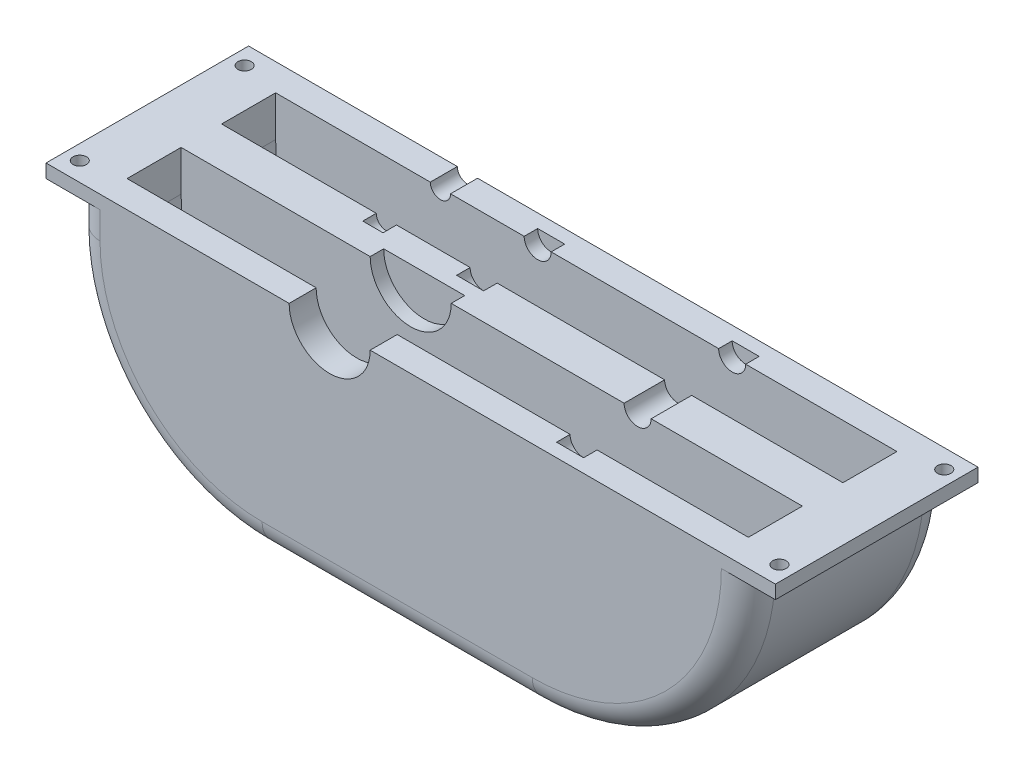
from build123d import *

# Parameters (mm, degrees)
BOSS_EXTRUDE1_DEPTH     = 37.5
SHELL1_T                = -10
SKETCH2_W               = 230
SKETCH2_H               = 15
BOSS_EXTRUDE3_DEPTH     = 75
SKETCH1_4_OUTSIDE_W     = 306.9
SKETCH1_4_OUTSIDE_H     = 141.9
CUT_EXTRUDE2_DEPTH      = 38.5
CUT_EXTRUDE2_DEPTH_BACK = 38.5
SKETCH4_W               = 10
SKETCH4_H               = 75
SKETCH4_R               = 2.5
BOSS_EXTRUDE4_DEPTH     = 5
FILLET1_R               = 10
SKETCH3_R               = 3.75
CUT_EXTRUDE3_DEPTH      = 35
CUT_EXTRUDE4_START      = -75
SKETCH3_13_R            = 15
CUT_EXTRUDE4_DEPTH      = 35
CUT_EXTRUDE5_START      = -5
CUT_EXTRUDE5_DEPTH      = 65
CUT_EXTRUDE6_START      = -5
CUT_EXTRUDE6_DEPTH      = 30


with BuildPart() as part:
    # Sketch1 → Boss-Extrude1 (new body, symmetric)
    with BuildSketch(Plane.XY):
        with BuildLine():
            Line((125, 0), (-125, 0))
            Line((-125, 0), (-125, -15))
            ThreePointArc((-125, -15), (-104.497474683, -64.497474683), (-55, -85))
            Line((-55, -85), (45, -85))
            ThreePointArc((45, -85), (101.568542495, -61.568542495), (125, -5))
            Line((125, -5), (125, 0))
        make_face()
    extrude(amount=BOSS_EXTRUDE1_DEPTH, both=True)

    # Shell1
    shell1_openings = [part.faces().sort_by_distance(p)[0] for p in [
        (0, 0, 0),
    ]]
    offset(amount=SHELL1_T, openings=shell1_openings, kind=Kind.INTERSECTION)

    # Sketch2 → Boss-Extrude3 (add)
    with BuildSketch(Plane(origin=(0, 0, 0), x_dir=(1, 0, 0), z_dir=(0, 1, 0))):
        Rectangle(SKETCH2_W, SKETCH2_H)
    extrude(amount=-BOSS_EXTRUDE3_DEPTH)

    # Sketch1_4 outside → Cut-Extrude2 (cut, two sides)
    with BuildSketch(Plane.XY) as cut_extrude2_sk:
        with Locations((0, -42.5)):
            Rectangle(SKETCH1_4_OUTSIDE_W, SKETCH1_4_OUTSIDE_H)
        with BuildLine():
            Line((125, 0), (-125, 0))
            Line((-125, 0), (-125, -15))
            ThreePointArc((-125, -15), (-104.497474683, -64.497474683), (-55, -85))
            Line((-55, -85), (45, -85))
            ThreePointArc((45, -85), (101.568542495, -61.568542495), (125, -5))
            Line((125, -5), (125, 0))
        make_face(mode=Mode.SUBTRACT)
    extrude(amount=CUT_EXTRUDE2_DEPTH, mode=Mode.SUBTRACT)
    extrude(cut_extrude2_sk.sketch, amount=-CUT_EXTRUDE2_DEPTH_BACK, mode=Mode.SUBTRACT)

    # Sketch4 → Boss-Extrude4 (add)
    with BuildSketch(Plane(origin=(0, 0, 0), x_dir=(1, 0, 0), z_dir=(0, 1, 0))):
        with Locations((-130, 0)):
            Rectangle(SKETCH4_W, SKETCH4_H)
        with Locations((-129.5, -30.5)):
            Circle(SKETCH4_R, mode=Mode.SUBTRACT)
        with Locations((-129.5, 30.5)):
            Circle(SKETCH4_R, mode=Mode.SUBTRACT)
        with Locations((130, 0)):
            Rectangle(SKETCH4_W, SKETCH4_H)
        with Locations((129.5, 30.5)):
            Circle(SKETCH4_R, mode=Mode.SUBTRACT)
        with Locations((129.5, -30.5)):
            Circle(SKETCH4_R, mode=Mode.SUBTRACT)
    extrude(amount=-BOSS_EXTRUDE4_DEPTH)

    # Fillet1
    fillet1_edges = [part.edges().sort_by_distance(p)[0] for p in [
        (-125, -10, -37.5),
        (-125, -10, 37.5),
        (-5, -85, 37.5),
        (-104.497474683, -64.497474683, 37.5),
        (-104.497474683, -64.497474683, -37.5),
        (-5, -85, -37.5),
        (101.568542495, -61.568542495, -37.5),
        (101.568542495, -61.568542495, 37.5),
    ]]
    fillet(fillet1_edges, radius=FILLET1_R)

    # Sketch3 → Cut-Extrude3 (cut)
    with BuildSketch(Plane(origin=(0, 0, -37.5), x_dir=(-1, 0, 0), z_dir=(0, 0, -1))):
        with Locations((54, 0)):
            Circle(SKETCH3_R)
    extrude(amount=-CUT_EXTRUDE3_DEPTH, mode=Mode.SUBTRACT)

    # Sketch3_13 → Cut-Extrude4 (cut)
    with BuildSketch(Plane(origin=(0, 0, -37.5), x_dir=(-1, 0, 0), z_dir=(0, 0, -1)).offset(CUT_EXTRUDE4_START)):
        with Locations((30, 0)):
            Circle(SKETCH3_13_R)
    extrude(amount=CUT_EXTRUDE4_DEPTH, mode=Mode.SUBTRACT)

    # Sketch3_14 → Cut-Extrude5 (cut)
    with BuildSketch(Plane(origin=(0, 0, -37.5), x_dir=(-1, 0, 0), z_dir=(0, 0, -1)).offset(CUT_EXTRUDE5_START)):
        with BuildLine():
            Line((-59, 0), (-49, 0))
            ThreePointArc((-49, 0), (-54, 5), (-59, 0))
        make_face()
        with BuildLine():
            ThreePointArc((-59, 0), (-54, -5), (-49, 0))
            Line((-49, 0), (-59, 0))
        make_face()
    extrude(amount=-CUT_EXTRUDE5_DEPTH, mode=Mode.SUBTRACT)

    # Sketch3_15 → Cut-Extrude6 (cut)
    with BuildSketch(Plane(origin=(0, 0, -37.5), x_dir=(-1, 0, 0), z_dir=(0, 0, -1)).offset(CUT_EXTRUDE6_START)):
        with BuildLine():
            Line((15, 0), (23, 0))
            ThreePointArc((23, 0), (20.581988897, 4.281744193), (15.666666667, 4.422166387))
            ThreePointArc((15.666666667, 4.422166387), (15.167603026, 2.236067977), (15, 0))
        make_face()
        with BuildLine():
            ThreePointArc((15.666666667, -4.422166387), (20.581988897, -4.281744193), (23, 0))
            Line((23, 0), (15, 0))
            ThreePointArc((15, 0), (15.167603026, -2.236067977), (15.666666667, -4.422166387))
        make_face()
        with BuildLine():
            ThreePointArc((15, 0), (15.167603026, 2.236067977), (15.666666667, 4.422166387))
            ThreePointArc((15.666666667, 4.422166387), (13.718255807, 2.581988897), (13, 0))
            Line((13, 0), (15, 0))
        make_face()
        with BuildLine():
            ThreePointArc((13, 0), (13.718255807, -2.581988897), (15.666666667, -4.422166387))
            ThreePointArc((15.666666667, -4.422166387), (15.167603026, -2.236067977), (15, 0))
            Line((15, 0), (13, 0))
        make_face()
    extrude(amount=-CUT_EXTRUDE6_DEPTH, mode=Mode.SUBTRACT)


solid = part.part
